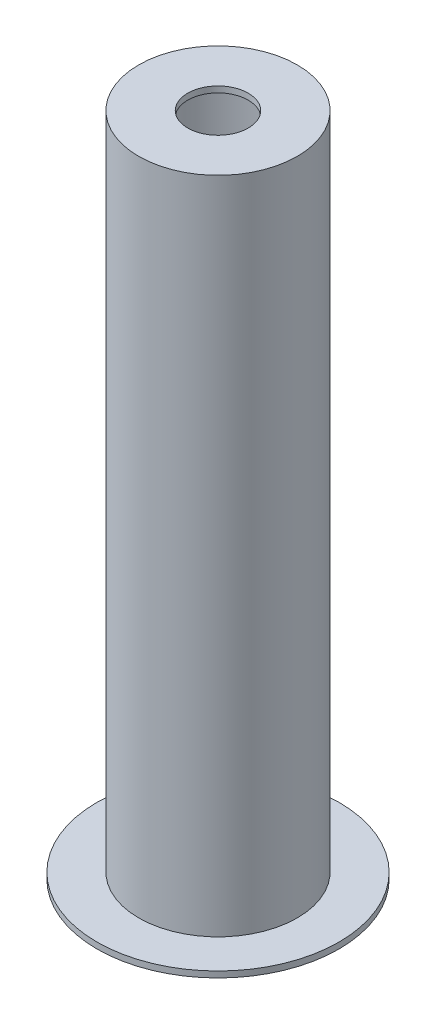
from build123d import *


with BuildPart() as part:
    # Esboço1 → Revolução1 (revolve)
    with BuildSketch(Plane.XY):
        Polygon((50, 1100), (131, 1100), (131, 10), (200, 10), (200, 0), (119, 0), (119, 10), (125, 10), (125, 1090), (50, 1090), align=None)
    revolve(axis=Axis((0, 0, 0), (0, 1, 0)))


solid = part.part
